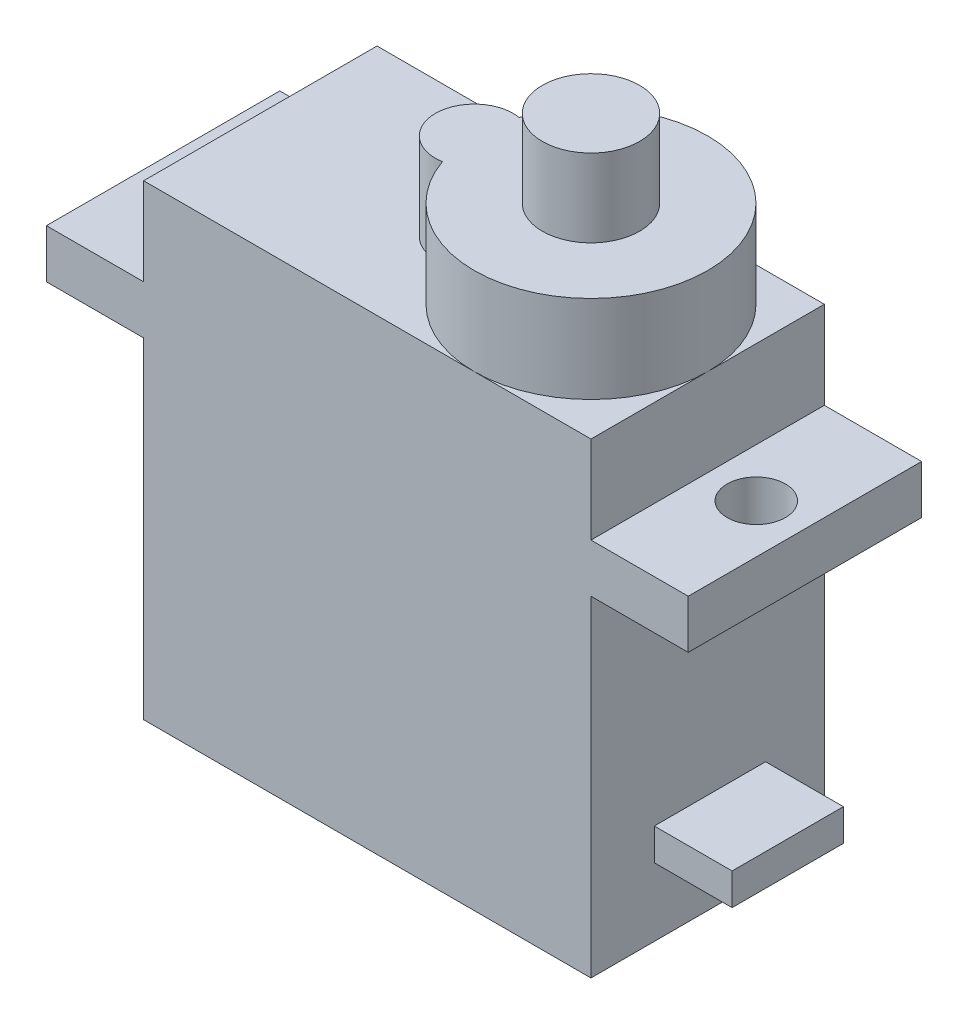
from build123d import *

# Parameters (mm, degrees)
SKETCH2_W           = 23
SKETCH2_H           = 12
BOSS_EXTRUDE1_DEPTH = 24
BOSS_EXTRUDE2_DEPTH = 4.5
SKETCH4_R           = 2.5
BOSS_EXTRUDE3_DEPTH = 4
SKETCH5_W           = 12
SKETCH5_H           = 2.5
BOSS_EXTRUDE4_DEPTH = 5
SKETCH6_W           = 12
SKETCH6_H           = 2.5
BOSS_EXTRUDE5_DEPTH = 5
SKETCH7_R           = 1.5
CUT_EXTRUDE1_DEPTH  = 5
SKETCH8_W           = 5.723155949
SKETCH8_H           = 1.635187414
BOSS_EXTRUDE6_DEPTH = 4


with BuildPart() as part:
    # Sketch2 → Boss-Extrude1 (new body)
    with BuildSketch(Plane(origin=(0, 0, 0), x_dir=(1, 0, 0), z_dir=(0, 1, 0))):
        with Locations((-0.097292724, -1.232656514)):
            Rectangle(SKETCH2_W, SKETCH2_H)
    extrude(amount=BOSS_EXTRUDE1_DEPTH)

    # Sketch3 → Boss-Extrude2 (add)
    with BuildSketch(Plane(origin=(0, 24, 0), x_dir=(1, 0, 0), z_dir=(0, 1, 0))):
        with BuildLine():
            ThreePointArc((-0.263959391, -3.204683109), (11.402707276, -1.232656514), (-0.263959391, 0.73937008))
            ThreePointArc((-0.263959391, 0.73937008), (-2.597292724, -1.232656514), (-0.263959391, -3.204683109))
        make_face()
    extrude(amount=BOSS_EXTRUDE2_DEPTH)

    # Sketch4 → Boss-Extrude3 (add)
    with BuildSketch(Plane(origin=(0, 28.5, 0), x_dir=(1, 0, 0), z_dir=(0, 1, 0))):
        with Locations((5.402707276, -1.232656514)):
            Circle(SKETCH4_R)
    extrude(amount=BOSS_EXTRUDE3_DEPTH)

    # Sketch5 → Boss-Extrude4 (add)
    with BuildSketch(Plane(origin=(11.402707276, 0, 0), x_dir=(0, 0, -1), z_dir=(1, 0, 0))):
        with Locations((-1.232656514, 18.25)):
            Rectangle(SKETCH5_W, SKETCH5_H)
    extrude(amount=BOSS_EXTRUDE4_DEPTH)

    # Sketch6 → Boss-Extrude5 (add)
    with BuildSketch(Plane.ZY.offset(11.597292724)):
        with Locations((1.232656514, 18.25)):
            Rectangle(SKETCH6_W, SKETCH6_H)
    extrude(amount=BOSS_EXTRUDE5_DEPTH)

    # Sketch7 → Cut-Extrude1 (cut)
    with BuildSketch(Plane(origin=(0, 19.5, 0), x_dir=(1, 0, 0), z_dir=(0, 1, 0))):
        with Locations((-14.097292724, -1.232656514)):
            Circle(SKETCH7_R)
        with Locations((13.902707276, -1.232656514)):
            Circle(SKETCH7_R)
    extrude(amount=-CUT_EXTRUDE1_DEPTH, mode=Mode.SUBTRACT)

    # Sketch8 → Boss-Extrude6 (add)
    with BuildSketch(Plane(origin=(11.402707276, 0, 0), x_dir=(0, 0, -1), z_dir=(1, 0, 0))):
        with Locations((-1.115857414, 4.321891812)):
            Rectangle(SKETCH8_W, SKETCH8_H)
    extrude(amount=BOSS_EXTRUDE6_DEPTH)


solid = part.part
